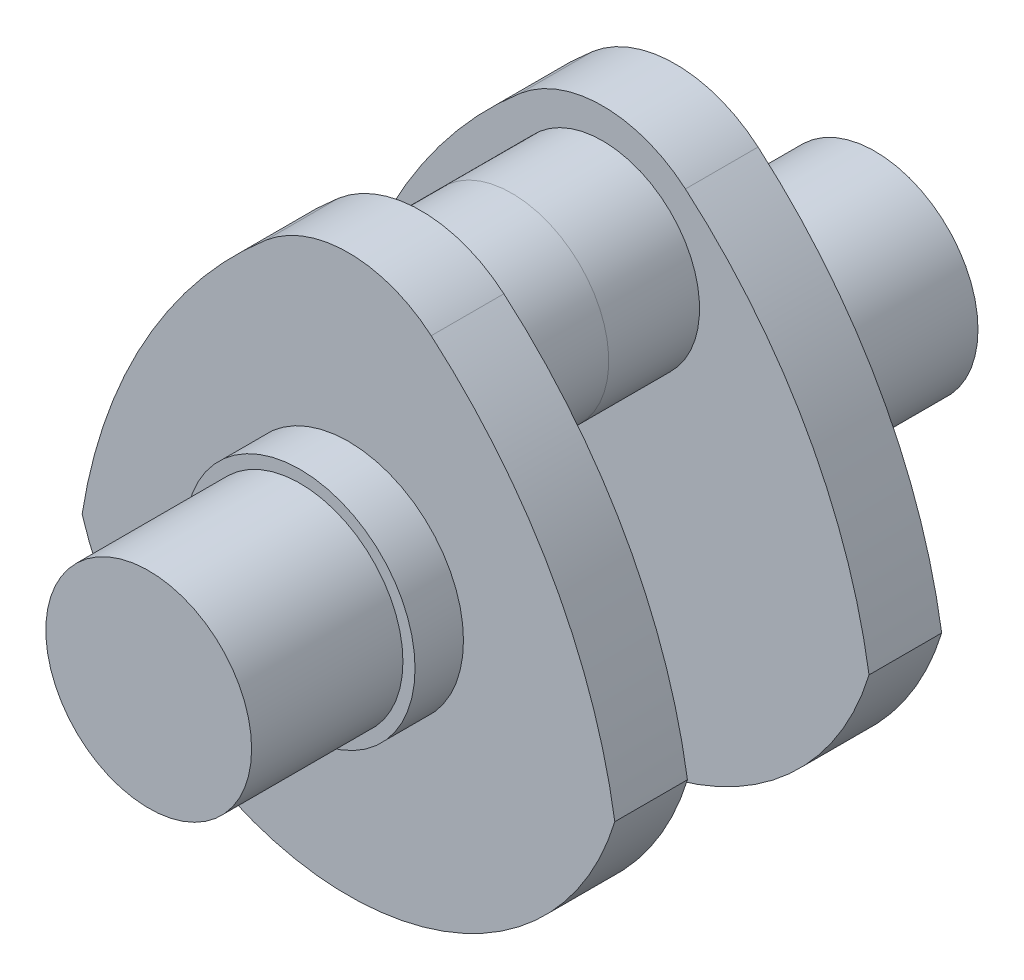
from build123d import *

# Parameters (mm, degrees)
SKETCH1_R           = 17
BOSS_EXTRUDE1_DEPTH = 25
SKETCH2_R           = 19
BOSS_EXTRUDE2_DEPTH = 8
BOSS_EXTRUDE3_DEPTH = 12
SKETCH4_R           = 16
BOSS_EXTRUDE4_DEPTH = 15


with BuildPart() as part:
    # Sketch1 → Boss-Extrude1 (new body)
    with BuildSketch(Plane.XY):
        Circle(SKETCH1_R)
    extrude(amount=BOSS_EXTRUDE1_DEPTH)

    # Sketch2 → Boss-Extrude2 (add)
    with BuildSketch(Plane.XY):
        Circle(SKETCH2_R)
    extrude(amount=-BOSS_EXTRUDE2_DEPTH)

    # Sketch3 → Boss-Extrude3 (add)
    with BuildSketch(Plane(origin=(0, 0, -8), x_dir=(-1, 0, 0), z_dir=(0, 0, -1))):
        with BuildLine():
            ThreePointArc((-44, -13.416407865), (0, -46), (44, -13.416407865))
            ThreePointArc((44, -13.416407865), (33.683444249, 16.469257624), (13.668094758, 40.943123461))
            ThreePointArc((13.668094758, 40.943123461), (0, 46), (-13.668094758, 40.943123461))
            ThreePointArc((-13.668094758, 40.943123461), (-33.683444249, 16.469257624), (-44, -13.416407865))
        make_face()
    extrude(amount=BOSS_EXTRUDE3_DEPTH)

    # Sketch4 → Boss-Extrude4 (add)
    with BuildSketch(Plane(origin=(0, 0, -20), x_dir=(-1, 0, 0), z_dir=(0, 0, -1))):
        with Locations((0, 25)):
            Circle(SKETCH4_R)
    extrude(amount=BOSS_EXTRUDE4_DEPTH)


with BuildPart() as body_2:
    # Mirror1: mirrored copy
    add(part.part.mirror(Plane(origin=(0, 25, -35), x_dir=(1, 0, 0), z_dir=(0, 0, -1))))


solid = Compound([part.part, body_2.part])
